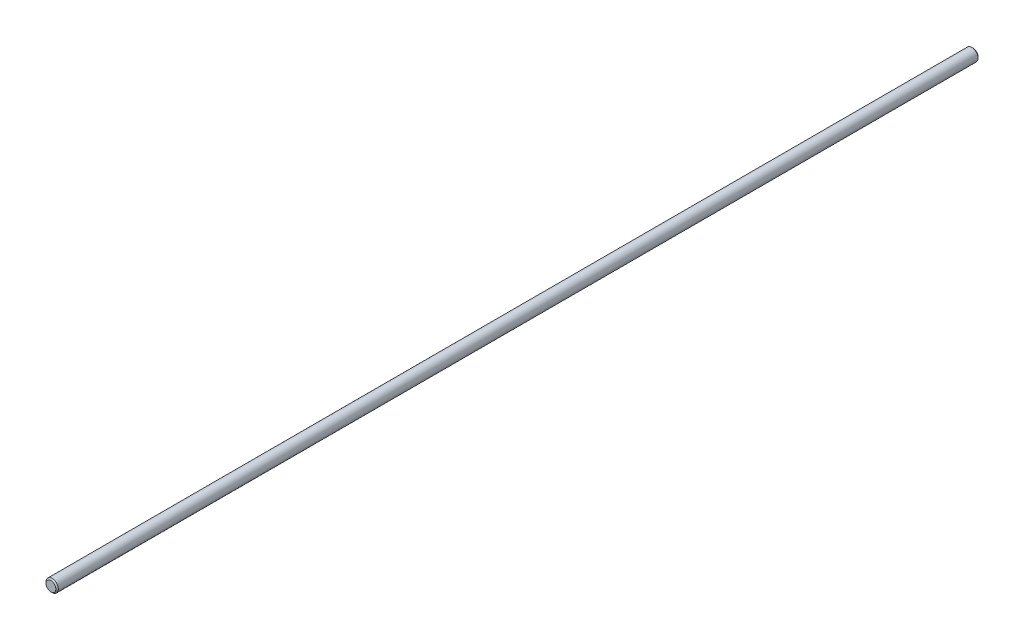
from build123d import *

# Parameters (mm, degrees)
SKETCH1_R      = 8
EXTRUDE1_DEPTH = 600
CHAMFER1_SIZE  = 1.6


with BuildPart() as part:
    # Sketch1 → Extrude1 (new body, symmetric)
    with BuildSketch(Plane.XY):
        Circle(SKETCH1_R)
    extrude(amount=EXTRUDE1_DEPTH, both=True)

    # Chamfer1
    chamfer1_edges = [part.edges().sort_by_distance(p)[0] for p in [
        (-8, 0, -600),
        (-8, 0, 600),
    ]]
    chamfer(chamfer1_edges, length=CHAMFER1_SIZE)


solid = part.part
